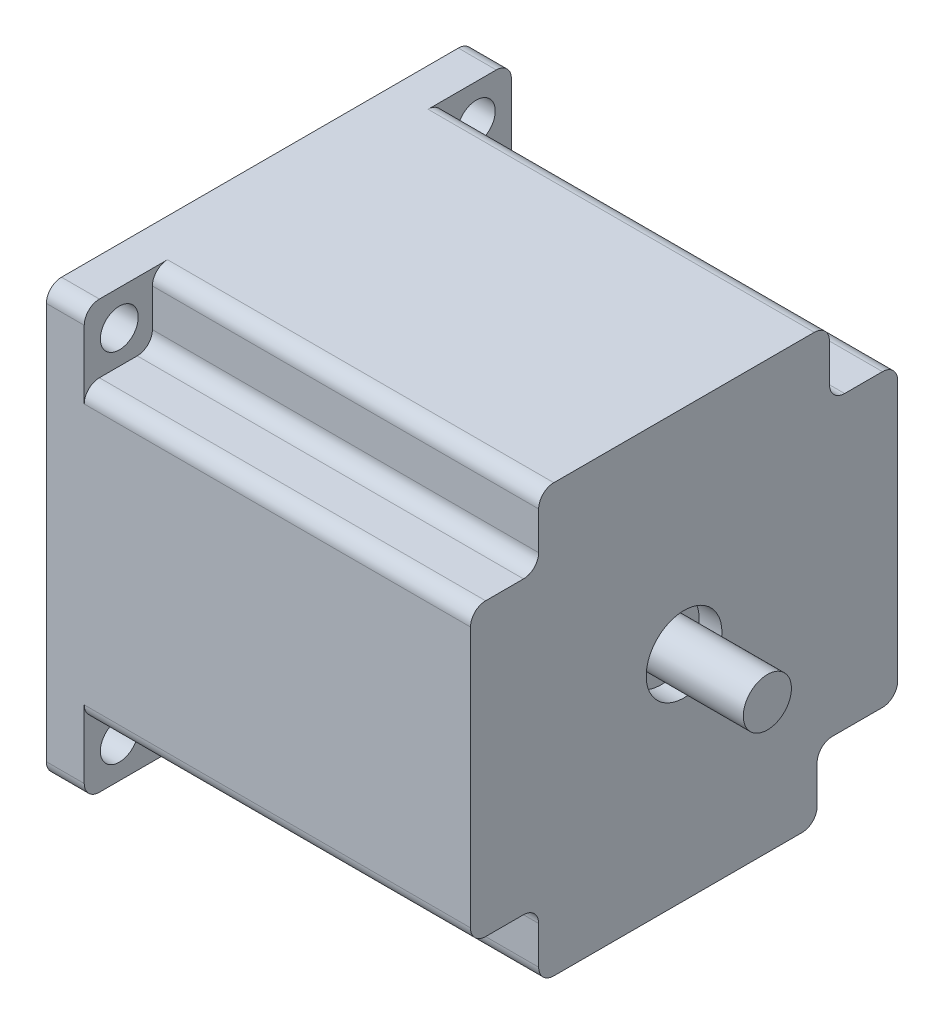
from build123d import *

# Parameters (mm, degrees)
SKETCH1_W           = 56.4
SKETCH1_H           = 56.4
SKETCH1_R           = 2.5
BOSS_EXTRUDE1_DEPTH = 5
BOSS_EXTRUDE2_DEPTH = 51
SKETCH3_R           = 5
CUT_EXTRUDE1_DEPTH  = 3
SKETCH5_R           = 3.175
BOSS_EXTRUDE3_DEPTH = 14
SKETCH6_R           = 19
BOSS_EXTRUDE4_DEPTH = 1.5
SKETCH7_R           = 5
CUT_EXTRUDE2_DEPTH  = 3
SKETCH9_R           = 3.175
BOSS_EXTRUDE5_DEPTH = 23
FILLET1_R           = 2
FILLET2_R           = 2
FILLET3_R           = 2
FILLET4_R           = 2
FILLET5_R           = 2
FILLET6_R           = 2
FILLET7_R           = 2
FILLET8_R           = 2
FILLET9_R           = 2
FILLET10_R          = 2
FILLET11_R          = 2
FILLET12_R          = 2
FILLET13_R          = 2
FILLET14_R          = 2
FILLET15_R          = 2
FILLET16_R          = 2


with BuildPart() as part:
    # Sketch1 → Boss-Extrude1 (new body)
    with BuildSketch(Plane(origin=(0, 0, 0), x_dir=(0, 0, -1), z_dir=(1, 0, 0))):
        Rectangle(SKETCH1_W, SKETCH1_H)
        with Locations((-23.57, 23.57)):
            Circle(SKETCH1_R, mode=Mode.SUBTRACT)
        with Locations((23.57, 23.57)):
            Circle(SKETCH1_R, mode=Mode.SUBTRACT)
        with Locations((23.57, -23.57)):
            Circle(SKETCH1_R, mode=Mode.SUBTRACT)
        with Locations((-23.57, -23.57)):
            Circle(SKETCH1_R, mode=Mode.SUBTRACT)
    extrude(amount=BOSS_EXTRUDE1_DEPTH)

    # Sketch2 → Boss-Extrude2 (add)
    with BuildSketch(Plane(origin=(5, 0, 0), x_dir=(0, 0, -1), z_dir=(1, 0, 0))):
        Polygon((-28.2, 19.2), (-19.2, 19.2), (-19.2, 28.2), (19.2, 28.2), (19.2, 19.2), (28.2, 19.2), (28.2, -19.2), (17.566571472, -19.2), (17.566571472, -28.2), (-19.2, -28.2), (-19.2, -19.2), (-28.2, -19.2), align=None)
    extrude(amount=BOSS_EXTRUDE2_DEPTH)

    # Sketch3 → Cut-Extrude1 (cut)
    with BuildSketch(Plane(origin=(56, 0, 0), x_dir=(0, 0, -1), z_dir=(1, 0, 0))):
        Circle(SKETCH3_R)
    extrude(amount=-CUT_EXTRUDE1_DEPTH, mode=Mode.SUBTRACT)

    # Sketch5 → Boss-Extrude3 (add)
    with BuildSketch(Plane(origin=(53, 0, 0), x_dir=(0, 0, -1), z_dir=(1, 0, 0))):
        Circle(SKETCH5_R)
    extrude(amount=BOSS_EXTRUDE3_DEPTH)

    # Sketch6 → Boss-Extrude4 (add)
    with BuildSketch(Plane.ZY):
        Circle(SKETCH6_R)
    extrude(amount=BOSS_EXTRUDE4_DEPTH)

    # Sketch7 → Cut-Extrude2 (cut)
    with BuildSketch(Plane.ZY.offset(1.5)):
        Circle(SKETCH7_R)
    extrude(amount=-CUT_EXTRUDE2_DEPTH, mode=Mode.SUBTRACT)

    # Sketch9 → Boss-Extrude5 (add)
    with BuildSketch(Plane.ZY.offset(-1.5)):
        Circle(SKETCH9_R)
    extrude(amount=BOSS_EXTRUDE5_DEPTH)

    # Fillet1
    fillet1_edges = [part.edges().sort_by_distance(p)[0] for p in [
        (2.5, 28.2, 28.2),
    ]]
    fillet(fillet1_edges, radius=FILLET1_R)

    # Fillet2
    fillet2_edges = [part.edges().sort_by_distance(p)[0] for p in [
        (2.5, 28.2, -28.2),
    ]]
    fillet(fillet2_edges, radius=FILLET2_R)

    # Fillet3
    fillet3_edges = [part.edges().sort_by_distance(p)[0] for p in [
        (2.5, -28.2, -28.2),
    ]]
    fillet(fillet3_edges, radius=FILLET3_R)

    # Fillet4
    fillet4_edges = [part.edges().sort_by_distance(p)[0] for p in [
        (2.5, -28.2, 28.2),
    ]]
    fillet(fillet4_edges, radius=FILLET4_R)

    # Fillet5
    fillet5_edges = [part.edges().sort_by_distance(p)[0] for p in [
        (30.5, 28.2, -19.2),
    ]]
    fillet(fillet5_edges, radius=FILLET5_R)

    # Fillet6
    fillet6_edges = [part.edges().sort_by_distance(p)[0] for p in [
        (30.5, 19.2, -28.2),
    ]]
    fillet(fillet6_edges, radius=FILLET6_R)

    # Fillet7
    fillet7_edges = [part.edges().sort_by_distance(p)[0] for p in [
        (30.5, -19.2, -28.2),
    ]]
    fillet(fillet7_edges, radius=FILLET7_R)

    # Fillet8
    fillet8_edges = [part.edges().sort_by_distance(p)[0] for p in [
        (30.5, -28.2, -17.566571472),
    ]]
    fillet(fillet8_edges, radius=FILLET8_R)

    # Fillet9
    fillet9_edges = [part.edges().sort_by_distance(p)[0] for p in [
        (30.5, -28.2, 19.2),
    ]]
    fillet(fillet9_edges, radius=FILLET9_R)

    # Fillet10
    fillet10_edges = [part.edges().sort_by_distance(p)[0] for p in [
        (30.5, -19.2, 28.2),
    ]]
    fillet(fillet10_edges, radius=FILLET10_R)

    # Fillet11
    fillet11_edges = [part.edges().sort_by_distance(p)[0] for p in [
        (30.5, 19.2, 28.2),
    ]]
    fillet(fillet11_edges, radius=FILLET11_R)

    # Fillet12
    fillet12_edges = [part.edges().sort_by_distance(p)[0] for p in [
        (30.5, 28.2, 19.2),
    ]]
    fillet(fillet12_edges, radius=FILLET12_R)

    # Fillet13
    fillet13_edges = [part.edges().sort_by_distance(p)[0] for p in [
        (30.5, 19.2, -19.2),
    ]]
    fillet(fillet13_edges, radius=FILLET13_R)

    # Fillet14
    fillet14_edges = [part.edges().sort_by_distance(p)[0] for p in [
        (30.5, -19.2, -17.566571472),
    ]]
    fillet(fillet14_edges, radius=FILLET14_R)

    # Fillet15
    fillet15_edges = [part.edges().sort_by_distance(p)[0] for p in [
        (30.5, -19.2, 19.2),
    ]]
    fillet(fillet15_edges, radius=FILLET15_R)

    # Fillet16
    fillet16_edges = [part.edges().sort_by_distance(p)[0] for p in [
        (30.5, 19.2, 19.2),
    ]]
    fillet(fillet16_edges, radius=FILLET16_R)


solid = part.part
